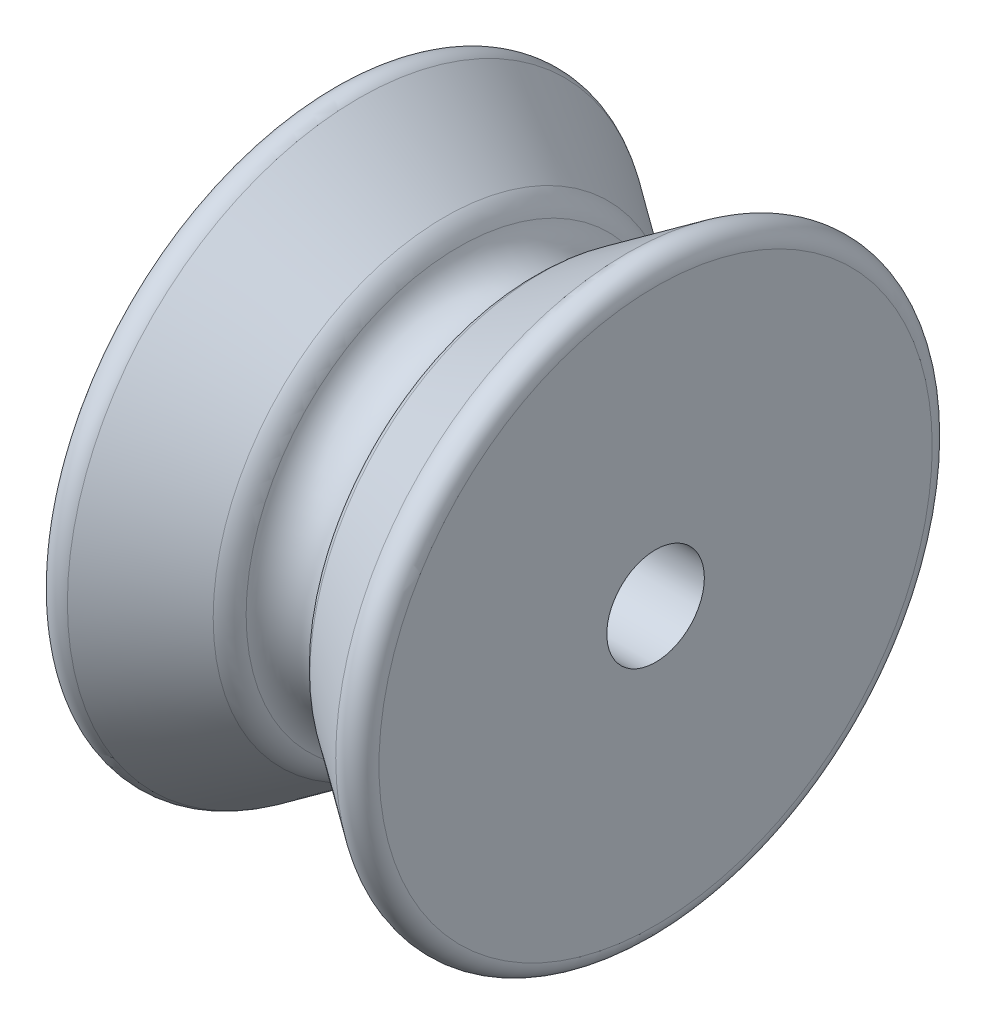
from build123d import *

# Parameters (mm, degrees)
SKETCH1_R           = 20
BOSS_EXTRUDE1_DEPTH = 18
SKETCH2_R           = 2.7
CUT_EXTRUDE1_DEPTH  = 18
FILLET1_R           = 1
FILLET2_R           = 2


with BuildPart() as part:
    # Sketch1 → Boss-Extrude1 (new body)
    with BuildSketch(Plane(origin=(0, 0, 0), x_dir=(0, 0, -1), z_dir=(1, 0, 0))):
        Circle(SKETCH1_R)
    extrude(amount=BOSS_EXTRUDE1_DEPTH)

    # Sketch2 → Cut-Extrude1 (cut)
    with BuildSketch(Plane(origin=(18, 0, 0), x_dir=(0, 0, -1), z_dir=(1, 0, 0))):
        Circle(SKETCH2_R)
    extrude(amount=-CUT_EXTRUDE1_DEPTH, mode=Mode.SUBTRACT)

    # Sketch3 → Cut-Revolve1 (revolve, cut)
    with BuildSketch(Plane.XY):
        with BuildLine():
            Line((11, 12.33250833), (27.091618379, 23.599980821))
            Line((27.091618379, 23.599980821), (-9.091618379, 23.599980821))
            Line((-9.091618379, 23.599980821), (7, 12.33250833))
            ThreePointArc((7, 12.33250833), (9, 10.33250833), (11, 12.33250833))
        make_face()
    revolve(axis=Axis((0, 0, 0), (1, 0, 0)), mode=Mode.SUBTRACT)

    # Fillet1
    fillet1_edges = [part.edges().sort_by_distance(p)[0] for p in [
        (0, -17.233961097, 0),
        (18, -17.233961097, 0),
    ]]
    fillet(fillet1_edges, radius=FILLET1_R)

    # Fillet2
    fillet2_edges = [part.edges().sort_by_distance(p)[0] for p in [
        (7, -12.33250833, 0),
        (11, -12.33250833, 0),
    ]]
    fillet(fillet2_edges, radius=FILLET2_R)


solid = part.part
